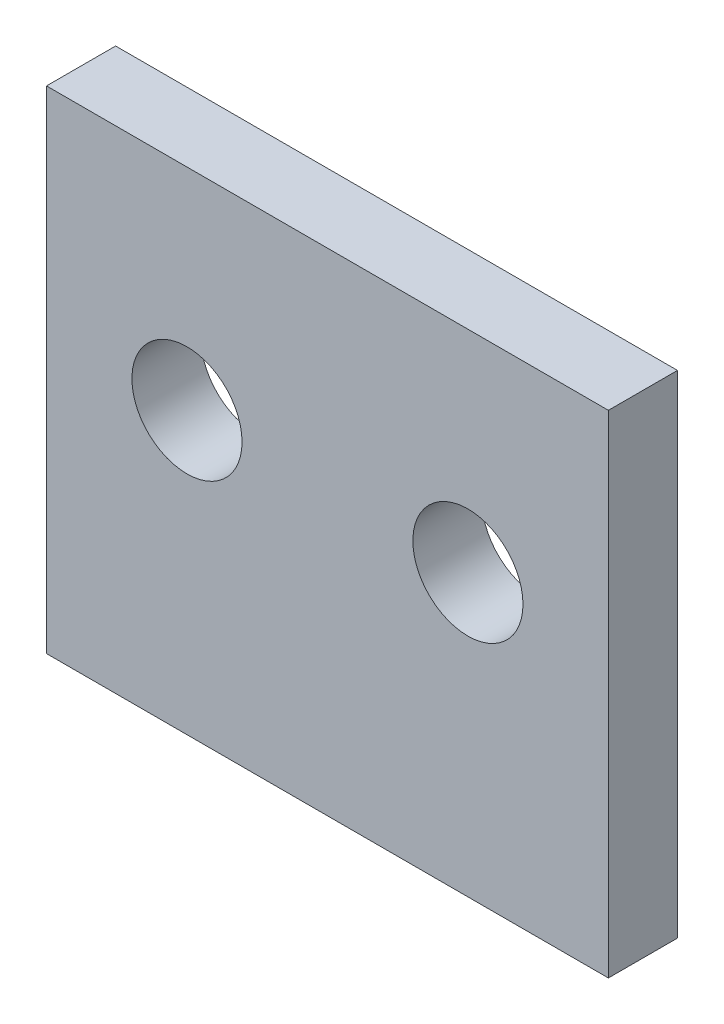
from build123d import *

# Parameters (mm, degrees)
SKETCH1_W           = 25.4
SKETCH1_H           = 22.225
SKETCH1_R           = 2.4892
BOSS_EXTRUDE1_DEPTH = 3.175
SKETCH2_W           = 0.0508
SKETCH2_H           = 22.225
CUT_EXTRUDE1_DEPTH  = 26.4


with BuildPart() as part:
    # Sketch1 → Boss-Extrude1 (new body)
    with BuildSketch(Plane.XY):
        with Locations((12.7, 237.8075)):
            Rectangle(SKETCH1_W, SKETCH1_H)
        with Locations((19.05, 239.395)):
            Circle(SKETCH1_R, mode=Mode.SUBTRACT)
        with Locations((6.35, 239.395)):
            Circle(SKETCH1_R, mode=Mode.SUBTRACT)
    extrude(amount=BOSS_EXTRUDE1_DEPTH)

    # Sketch2 → Cut-Extrude1 (cut, through all)
    with BuildSketch(Plane.ZY):
        with Locations((0.0254, 237.8075)):
            Rectangle(SKETCH2_W, SKETCH2_H)
    extrude(amount=-CUT_EXTRUDE1_DEPTH, mode=Mode.SUBTRACT)


solid = part.part
